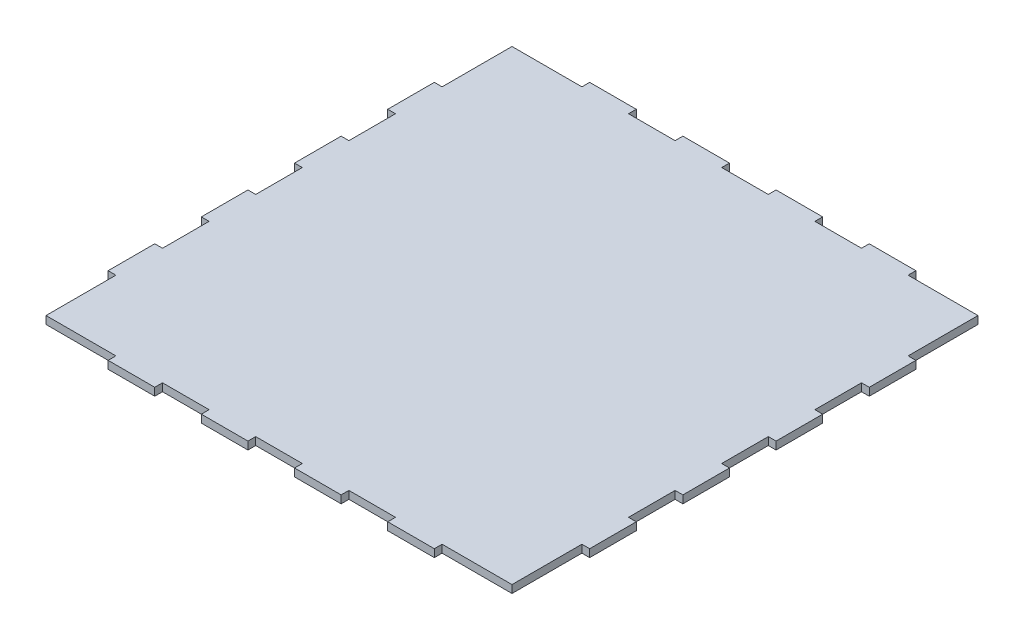
from build123d import *

# Parameters (mm, degrees)
ESQUISSE1_W                = 381
ESQUISSE1_H                = 381
BOSS_EXTRU_1_DEPTH         = 6.35
ESQUISSE2_W                = 38.1
ESQUISSE2_H                = 6.35
BOSS_EXTRU_2_DEPTH         = 6.35
R_P_TITION_LIN_AIRE1_COUNT = 4
R_P_TITION_LIN_AIRE1_PITCH = 76.2
SYM_TRIE1_COPY_1_SKETCH_W  = 38.1
SYM_TRIE1_COPY_1_SKETCH_H  = 6.35
SYM_TRIE1_COPY_1_DEPTH     = 6.35
SYM_TRIE1_COPY_2_SKETCH_W  = 38.1
SYM_TRIE1_COPY_2_SKETCH_H  = 6.35
SYM_TRIE1_COPY_2_DEPTH     = 6.35
SYM_TRIE1_COPY_3_SKETCH_W  = 38.1
SYM_TRIE1_COPY_3_SKETCH_H  = 6.35
SYM_TRIE1_COPY_3_DEPTH     = 6.35
ESQUISSE3_W                = 38.1
ESQUISSE3_H                = 6.35
BOSS_EXTRU_3_DEPTH         = 6.35
R_P_TITION_LIN_AIRE2_COUNT = 4
R_P_TITION_LIN_AIRE2_PITCH = 76.2
SYM_TRIE2_COPY_1_SKETCH_W  = 38.1
SYM_TRIE2_COPY_1_SKETCH_H  = 6.35
SYM_TRIE2_COPY_1_DEPTH     = 6.35
SYM_TRIE2_COPY_2_SKETCH_W  = 38.1
SYM_TRIE2_COPY_2_SKETCH_H  = 6.35
SYM_TRIE2_COPY_2_DEPTH     = 6.35
SYM_TRIE2_COPY_3_SKETCH_W  = 38.1
SYM_TRIE2_COPY_3_SKETCH_H  = 6.35
SYM_TRIE2_COPY_3_DEPTH     = 6.35


with BuildPart() as part:
    # Esquisse1 → Boss.-Extru.1 (new body)
    with BuildSketch(Plane(origin=(0, 0, 0), x_dir=(1, 0, 0), z_dir=(0, 1, 0))):
        Rectangle(ESQUISSE1_W, ESQUISSE1_H)
    extrude(amount=BOSS_EXTRU_1_DEPTH)

    # Esquisse2 → Boss.-Extru.2 (add)
    with BuildSketch(Plane(origin=(190.5, 0, 0), x_dir=(0, 0, -1), z_dir=(1, 0, 0))):
        with Locations((-114.3, 3.175)):
            Rectangle(ESQUISSE2_W, ESQUISSE2_H)
    boss_extru_2 = extrude(amount=BOSS_EXTRU_2_DEPTH)

    # Répétition linéaire1: Boss.-Extru.2 ×4
    with Locations(*[(0, 0, -i * R_P_TITION_LIN_AIRE1_PITCH) for i in range(1, R_P_TITION_LIN_AIRE1_COUNT)]):
        add(boss_extru_2)

    # Symétrie1: Boss.-Extru.2 across plane
    add(boss_extru_2.mirror(Plane(origin=(0, 0, 0), x_dir=(0, 0, 1), z_dir=(1, 0, 0))))

    # Symétrie1 copy 1 sketch → Symétrie1 copy 1 (add)
    with BuildSketch(Plane(origin=(-190.5, 0, -76.2), x_dir=(0, 0, -1), z_dir=(-1, 0, 0))):
        with Locations((-114.3, -3.175)):
            Rectangle(SYM_TRIE1_COPY_1_SKETCH_W, SYM_TRIE1_COPY_1_SKETCH_H)
    extrude(amount=SYM_TRIE1_COPY_1_DEPTH)

    # Symétrie1 copy 2 sketch → Symétrie1 copy 2 (add)
    with BuildSketch(Plane(origin=(-190.5, 0, -152.4), x_dir=(0, 0, -1), z_dir=(-1, 0, 0))):
        with Locations((-114.3, -3.175)):
            Rectangle(SYM_TRIE1_COPY_2_SKETCH_W, SYM_TRIE1_COPY_2_SKETCH_H)
    extrude(amount=SYM_TRIE1_COPY_2_DEPTH)

    # Symétrie1 copy 3 sketch → Symétrie1 copy 3 (add)
    with BuildSketch(Plane(origin=(-190.5, 0, -228.6), x_dir=(0, 0, -1), z_dir=(-1, 0, 0))):
        with Locations((-114.3, -3.175)):
            Rectangle(SYM_TRIE1_COPY_3_SKETCH_W, SYM_TRIE1_COPY_3_SKETCH_H)
    extrude(amount=SYM_TRIE1_COPY_3_DEPTH)

    # Esquisse3 → Boss.-Extru.3 (add)
    with BuildSketch(Plane.XY.offset(190.5)):
        with Locations((114.3, 3.175)):
            Rectangle(ESQUISSE3_W, ESQUISSE3_H)
    boss_extru_3 = extrude(amount=BOSS_EXTRU_3_DEPTH)

    # Répétition linéaire2: Boss.-Extru.3 ×4
    with Locations(*[(-i * R_P_TITION_LIN_AIRE2_PITCH, 0, 0) for i in range(1, R_P_TITION_LIN_AIRE2_COUNT)]):
        add(boss_extru_3)

    # Symétrie2: Boss.-Extru.3 across plane
    add(boss_extru_3.mirror(Plane.XY))

    # Symétrie2 copy 1 sketch → Symétrie2 copy 1 (add)
    with BuildSketch(Plane(origin=(-76.2, 0, -190.5), x_dir=(1, 0, 0), z_dir=(0, 0, -1))):
        with Locations((114.3, -3.175)):
            Rectangle(SYM_TRIE2_COPY_1_SKETCH_W, SYM_TRIE2_COPY_1_SKETCH_H)
    extrude(amount=SYM_TRIE2_COPY_1_DEPTH)

    # Symétrie2 copy 2 sketch → Symétrie2 copy 2 (add)
    with BuildSketch(Plane(origin=(-152.4, 0, -190.5), x_dir=(1, 0, 0), z_dir=(0, 0, -1))):
        with Locations((114.3, -3.175)):
            Rectangle(SYM_TRIE2_COPY_2_SKETCH_W, SYM_TRIE2_COPY_2_SKETCH_H)
    extrude(amount=SYM_TRIE2_COPY_2_DEPTH)

    # Symétrie2 copy 3 sketch → Symétrie2 copy 3 (add)
    with BuildSketch(Plane(origin=(-228.6, 0, -190.5), x_dir=(1, 0, 0), z_dir=(0, 0, -1))):
        with Locations((114.3, -3.175)):
            Rectangle(SYM_TRIE2_COPY_3_SKETCH_W, SYM_TRIE2_COPY_3_SKETCH_H)
    extrude(amount=SYM_TRIE2_COPY_3_DEPTH)


solid = part.part
